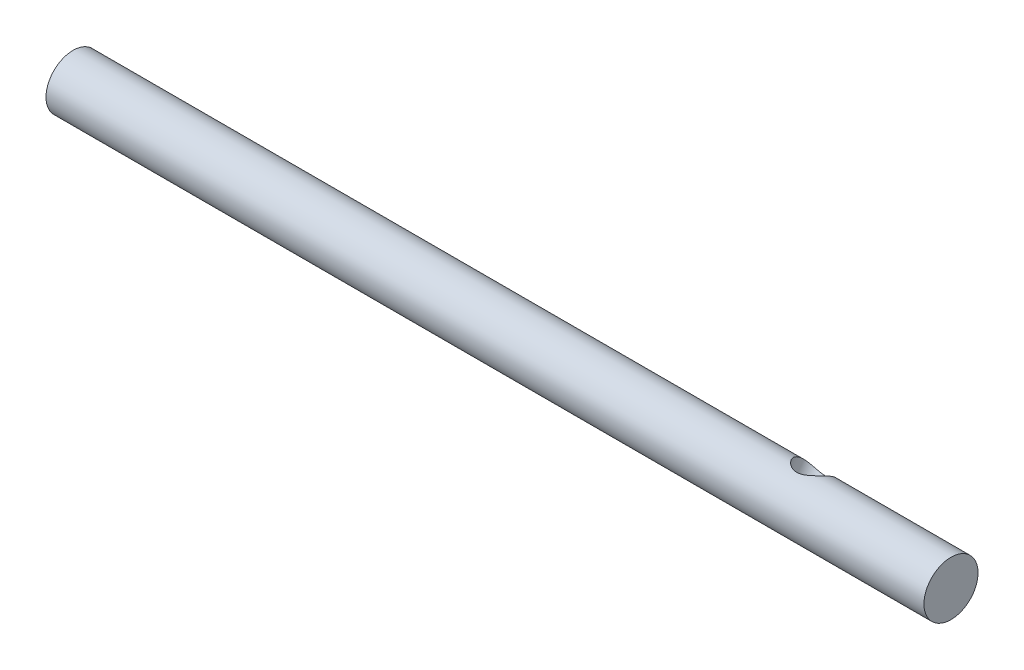
from build123d import *

# Parameters (mm, degrees)
SKETCH1_R           = 4
BOSS_EXTRUDE1_DEPTH = 75
SKETCH2_R           = 2.5
CUT_EXTRUDE1_DEPTH  = 1097
SKETCH3_W           = 40.4
SKETCH3_H           = 41.541480206
CUT_EXTRUDE2_DEPTH  = 5


with BuildPart() as part:
    # Sketch1 → Boss-Extrude1 (new body, symmetric)
    with BuildSketch(Plane(origin=(0, 0, 0), x_dir=(0, 0, -1), z_dir=(1, 0, 0))):
        Circle(SKETCH1_R)
    extrude(amount=BOSS_EXTRUDE1_DEPTH, both=True)

    # Sketch2 → Cut-Extrude1 (cut)
    with BuildSketch(Plane(origin=(-1373.627106081, 398.034078038, -1457.249478015), x_dir=(0, 0.520791654, 0.853683813), z_dir=(0, -0.853683813, 0.520791654))):
        with Locations((1036.737465208, -1406.127106081)):
            Circle(SKETCH2_R)
    extrude(amount=CUT_EXTRUDE1_DEPTH, mode=Mode.SUBTRACT)

    # Sketch3 → Cut-Extrude2 (cut, symmetric)
    with BuildSketch(Plane(origin=(0, 0, 0), x_dir=(1, 0, 0), z_dir=(0, 1, 0))):
        with Locations((75, 4)):
            Rectangle(SKETCH3_W, SKETCH3_H)
    extrude(amount=CUT_EXTRUDE2_DEPTH, both=True, mode=Mode.SUBTRACT)


solid = part.part
